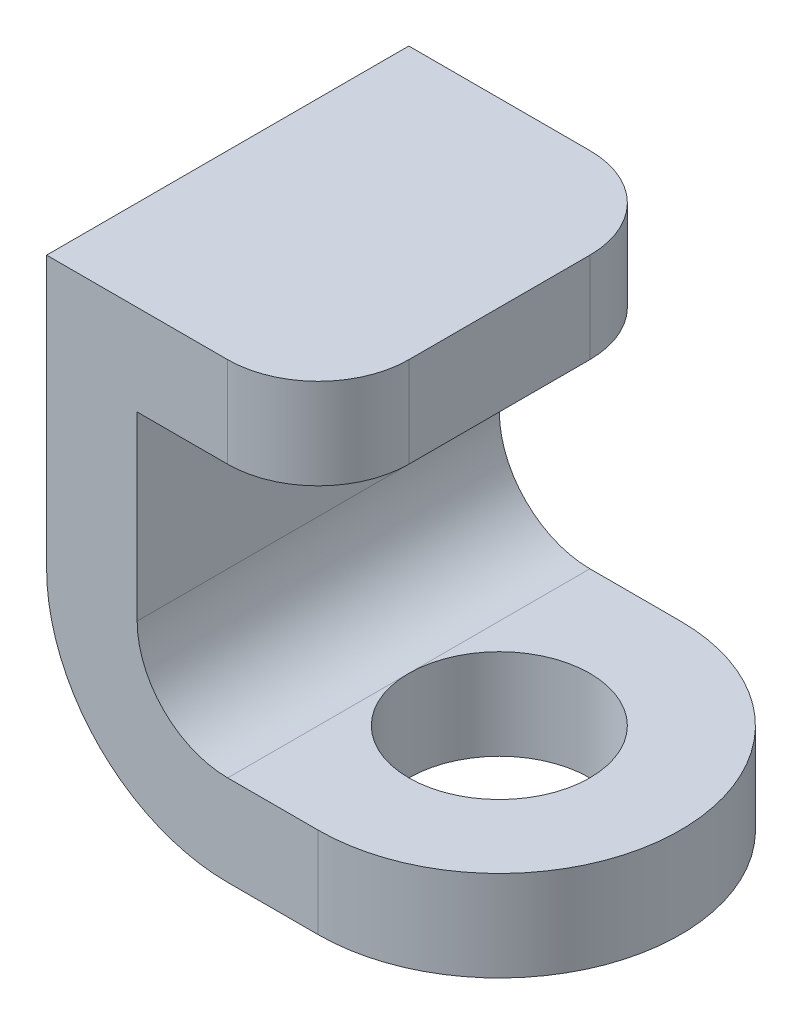
from build123d import *

# Parameters (mm, degrees)
SKETCH_1_R      = 5
EXTRUDE_1_DEPTH = 5
SKETCH_1_3_W    = 5
SKETCH_1_3_H    = 20
EXTRUDE_2_DEPTH = 25
SKETCH_2_W      = 20
SKETCH_2_H      = 5
EXTRUDE_3_DEPTH = 10
FILLET_1_R      = 5
FILLET_2_R      = 10
FILLET_3_R      = 5


with BuildPart() as part:
    # 草圖1 → 填料-伸長1 (new body)
    with BuildSketch(Plane(origin=(0, 0, 0), x_dir=(1, 0, 0), z_dir=(0, 1, 0))):
        with BuildLine():
            ThreePointArc((0, -10), (10, 0), (0, 10))
            Line((0, 10), (-10, 10))
            Line((-10, 10), (-10, -10))
            Line((-10, -10), (0, -10))
        make_face()
        with Locations(Location((0, 0, 0), (0, 0, 270))):
            Circle(SKETCH_1_R, mode=Mode.SUBTRACT)
    extrude(amount=EXTRUDE_1_DEPTH)

    # 草圖1<3> → 填料-伸長2 (add)
    with BuildSketch(Plane(origin=(0, 0, 0), x_dir=(1, 0, 0), z_dir=(0, 1, 0))):
        with Locations((-12.5, 0)):
            Rectangle(SKETCH_1_3_W, SKETCH_1_3_H)
    extrude(amount=EXTRUDE_2_DEPTH)

    # 草圖2 → 填料-伸長3 (add)
    with BuildSketch(Plane(origin=(-10, 0, 0), x_dir=(0, 0, -1), z_dir=(1, 0, 0))):
        with Locations((0, 22.5)):
            Rectangle(SKETCH_2_W, SKETCH_2_H)
    extrude(amount=EXTRUDE_3_DEPTH)

    # 圓角1
    fillet_1_edges = [part.edges().sort_by_distance(p)[0] for p in [
        (0, 22.5, 10),
        (0, 22.5, -10),
    ]]
    fillet(fillet_1_edges, radius=FILLET_1_R)

    # 圓角2
    fillet_2_edges = [part.edges().sort_by_distance(p)[0] for p in [
        (-15, 0, 0),
    ]]
    fillet(fillet_2_edges, radius=FILLET_2_R)

    # 圓角3
    fillet_3_edges = [part.edges().sort_by_distance(p)[0] for p in [
        (-10, 5, 0),
    ]]
    fillet(fillet_3_edges, radius=FILLET_3_R)


solid = part.part
